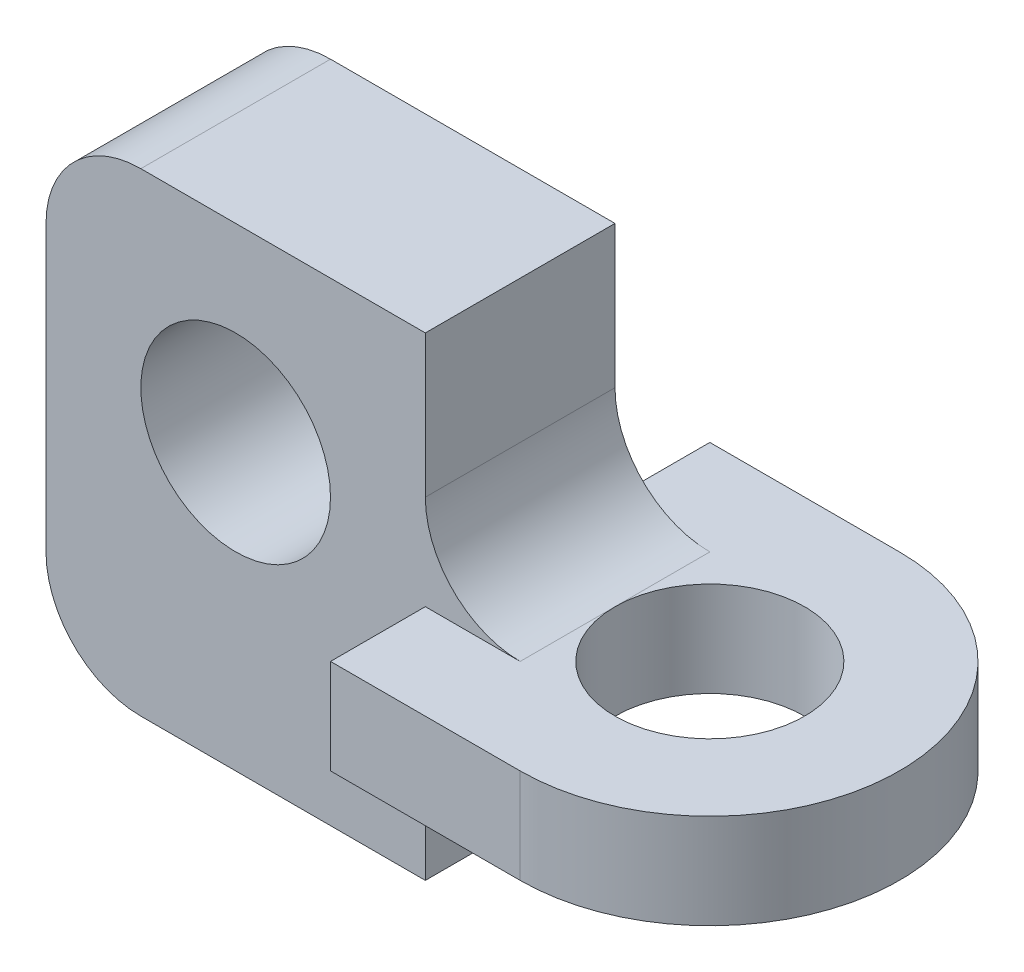
from build123d import *

# Parameters (mm, degrees)
SKETCH_1_R      = 5
EXTRUDE_1_DEPTH = 2.5
SKETCH_2_R      = 5
EXTRUDE_2_DEPTH = 5
FILLET_1_R      = 5
SCALE_1_SCALE   = 0.2


with BuildPart() as part:
    # 草圖1 → 填料-伸長1 (new, symmetric)
    with BuildSketch(Plane(origin=(0, 0, 0), x_dir=(1, 0, 0), z_dir=(0, 1, 0))):
        with BuildLine():
            Line((0, 10), (-10, 10))
            Line((-10, 10), (-10, -10))
            Line((-10, -10), (0, -10))
            ThreePointArc((0, -10), (10, 0), (0, 10))
        make_face()
        with Locations(Location((0, 0, 0), (0, 0, 270))):
            Circle(SKETCH_1_R, mode=Mode.SUBTRACT)
    extrude(amount=EXTRUDE_1_DEPTH, both=True)

    # 草圖2 → 填料-伸長2 (add, symmetric)
    with BuildSketch(Plane.XY):
        with BuildLine():
            Line((-30, 1.898257061), (-30, -5))
            ThreePointArc((-30, -5), (-28.535533906, -8.535533906), (-25, -10))
            Line((-25, -10), (-10, -10))
            Line((-10, -10), (-10, -2.5))
            Line((-10, -2.5), (-10, 2.5))
            Line((-10, 2.5), (-10, 15))
            Line((-10, 15), (-25, 15))
            ThreePointArc((-25, 15), (-28.535533906, 13.535533906), (-30, 10))
            Line((-30, 10), (-30, 1.898257061))
        make_face()
        with Locations((-20, 5)):
            Circle(SKETCH_2_R, mode=Mode.SUBTRACT)
    extrude(amount=EXTRUDE_2_DEPTH, both=True)

    # 圓角1
    fillet_1_edges = [part.edges().sort_by_distance(p)[0] for p in [
        (-10, -2.5, 0),
        (-10, 2.5, 0),
    ]]
    fillet(fillet_1_edges, radius=FILLET_1_R)


with BuildPart() as part_1:
    # 縮放比例1: scaled about (-14.947063882, 1.481061389, 0)
    add(part.part.scale(SCALE_1_SCALE).moved(Location((-11.957651106, 1.184849111, 0))))


solid = part_1.part
